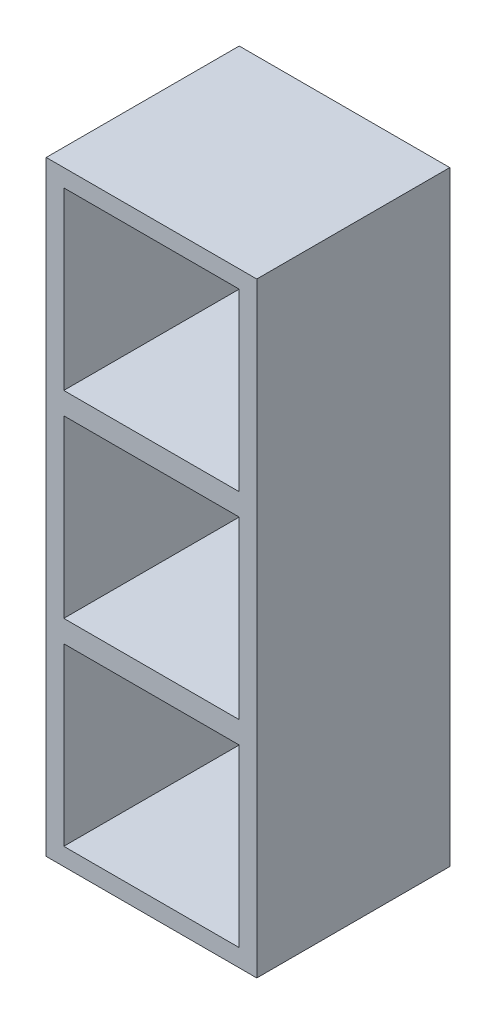
from build123d import *

# Parameters (mm, degrees)
CROQUIS1_W              = 48
CROQUIS1_H              = 138
SALIENTE_EXTRUIR1_DEPTH = 44
VACIADO1_T              = -4
CROQUIS2_W              = 40
CROQUIS2_H              = 5
SALIENTE_EXTRUIR2_DEPTH = 40


with BuildPart() as part:
    # Croquis1 → Saliente-Extruir1 (new body)
    with BuildSketch(Plane.XY):
        with Locations((24, 69)):
            Rectangle(CROQUIS1_W, CROQUIS1_H)
    extrude(amount=SALIENTE_EXTRUIR1_DEPTH)

    # Vaciado1
    vaciado1_openings = [part.faces().sort_by_distance(p)[0] for p in [
        (24, 69, 44),
    ]]
    offset(amount=VACIADO1_T, openings=vaciado1_openings, kind=Kind.INTERSECTION)

    # Croquis2 → Saliente-Extruir2 (add, through all)
    with BuildSketch(Plane.XY.offset(4)):
        with Locations((24, 46.5)):
            Rectangle(CROQUIS2_W, CROQUIS2_H)
        with Locations((24, 91.5)):
            Rectangle(CROQUIS2_W, CROQUIS2_H)
    extrude(amount=SALIENTE_EXTRUIR2_DEPTH)


solid = part.part
